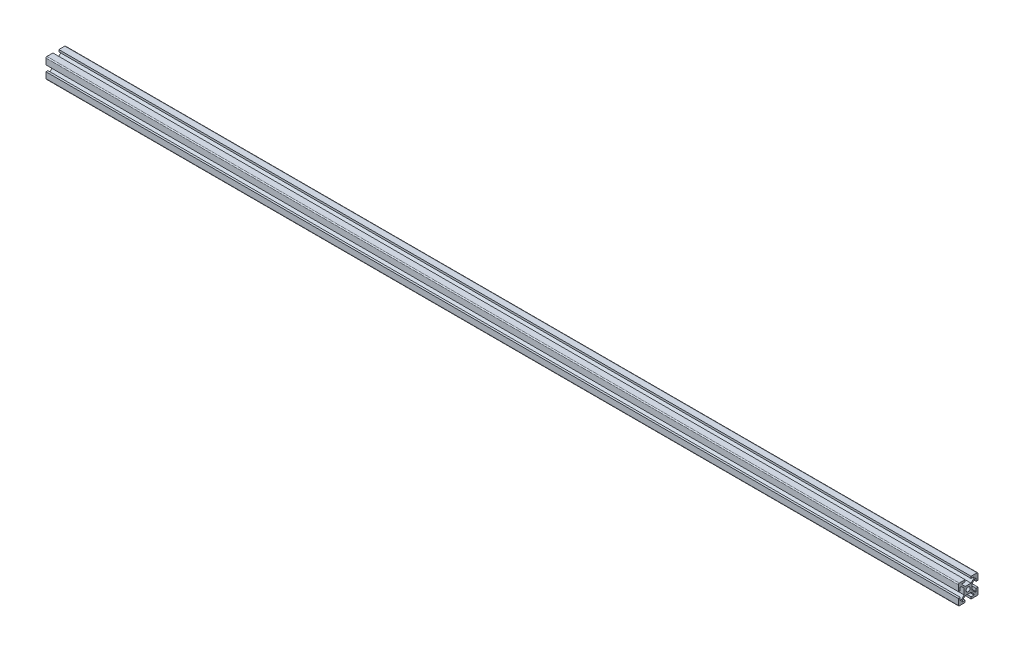
from build123d import *

# Parameters (mm, degrees)
SKETCH1_R           = 2.1
BOSS_EXTRUDE1_DEPTH = 925


with BuildPart() as part:
    # Sketch1 → Boss-Extrude1 (new body)
    with BuildSketch(Plane(origin=(0, 0, 0), x_dir=(0, 0, -1), z_dir=(1, 0, 0))):
        with BuildLine():
            Line((-10, 9), (-10, 3))
            Line((-10, 3), (-8, 3))
            Line((-8, 3), (-8, 6))
            Line((-8, 6), (-7.060660172, 6))
            Line((-7.060660172, 6), (-4, 2.939339828))
            Line((-4, 2.939339828), (-4, -2.939339828))
            Line((-4, -2.939339828), (-7.060660172, -6))
            Line((-7.060660172, -6), (-8, -6))
            Line((-8, -6), (-8, -3))
            Line((-8, -3), (-10, -3))
            Line((-10, -3), (-10, -9))
            ThreePointArc((-10, -9), (-9.707106781, -9.707106781), (-9, -10))
            Line((-9, -10), (-3, -10))
            Line((-3, -10), (-3, -8))
            Line((-3, -8), (-6, -8))
            Line((-6, -8), (-6, -7.060660172))
            Line((-6, -7.060660172), (-2.939339828, -4))
            Line((-2.939339828, -4), (2.939339828, -4))
            Line((2.939339828, -4), (6, -7.060660172))
            Line((6, -7.060660172), (6, -8))
            Line((6, -8), (3, -8))
            Line((3, -8), (3, -10))
            Line((3, -10), (9, -10))
            ThreePointArc((9, -10), (9.707106781, -9.707106781), (10, -9))
            Line((10, -9), (10, -3))
            Line((10, -3), (8, -3))
            Line((8, -3), (8, -6))
            Line((8, -6), (7.060660172, -6))
            Line((7.060660172, -6), (4, -2.939339828))
            Line((4, -2.939339828), (4, 2.939339828))
            Line((4, 2.939339828), (7.060660172, 6))
            Line((7.060660172, 6), (8, 6))
            Line((8, 6), (8, 3))
            Line((8, 3), (10, 3))
            Line((10, 3), (10, 9))
            ThreePointArc((10, 9), (9.707106781, 9.707106781), (9, 10))
            Line((9, 10), (3, 10))
            Line((3, 10), (3, 8))
            Line((3, 8), (6, 8))
            Line((6, 8), (6, 7.060660172))
            Line((6, 7.060660172), (2.939339828, 4))
            Line((2.939339828, 4), (-2.939339828, 4))
            Line((-2.939339828, 4), (-6, 7.060660172))
            Line((-6, 7.060660172), (-6, 8))
            Line((-6, 8), (-3, 8))
            Line((-3, 8), (-3, 10))
            Line((-3, 10), (-9, 10))
            ThreePointArc((-9, 10), (-9.707106781, 9.707106781), (-10, 9))
        make_face()
        Circle(SKETCH1_R, mode=Mode.SUBTRACT)
    extrude(amount=BOSS_EXTRUDE1_DEPTH)


solid = part.part
